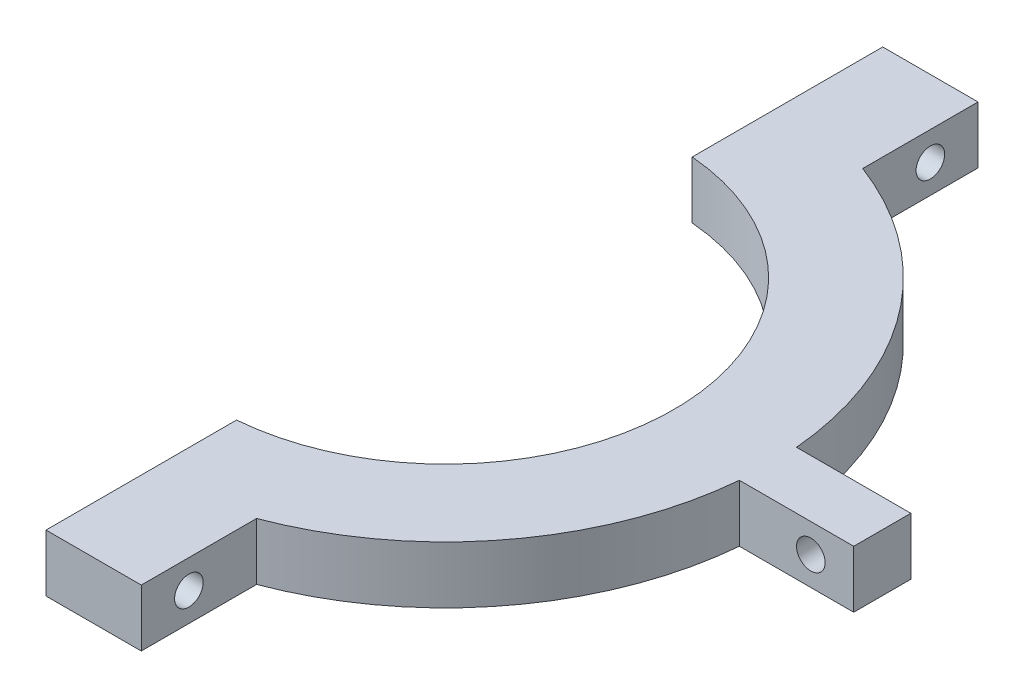
from build123d import *

# Parameters (mm, degrees)
BOSS_EXTRUDE1_DEPTH = 6
SKETCH3_R           = 1.5
CUT_EXTRUDE2_DEPTH  = 47.916521486
SKETCH4_R           = 1.5
CUT_EXTRUDE3_DEPTH  = 11


with BuildPart() as part:
    # Sketch1 → Boss-Extrude1 (new body)
    with BuildSketch(Plane(origin=(0, 0, 0), x_dir=(1, 0, 0), z_dir=(0, 1, 0))):
        with BuildLine():
            Line((2, 43.916521486), (2, 23.916521486))
            ThreePointArc((2, 23.916521486), (24, 0), (2, -23.916521486))
            Line((2, -23.916521486), (2, -43.916521486))
            Line((2, -43.916521486), (12, -43.916521486))
            Line((12, -43.916521486), (12, -31.811947441))
            ThreePointArc((12, -31.811947441), (27.082954224, -20.55513538), (33.867388444, -3))
            Line((33.867388444, -3), (45.867388444, -3))
            Line((45.867388444, -3), (45.867388444, 3))
            Line((45.867388444, 3), (33.867388444, 3))
            ThreePointArc((33.867388444, 3), (27.082954224, 20.55513538), (12, 31.811947441))
            Line((12, 31.811947441), (12, 43.916521486))
            Line((12, 43.916521486), (2, 43.916521486))
        make_face()
    extrude(amount=BOSS_EXTRUDE1_DEPTH)

    # Sketch3 → Cut-Extrude2 (cut, through all)
    with BuildSketch(Plane(origin=(0, 0, -3), x_dir=(-1, 0, 0), z_dir=(0, 0, -1))):
        with Locations((-41.367388444, 3)):
            Circle(SKETCH3_R)
    extrude(amount=-CUT_EXTRUDE2_DEPTH, mode=Mode.SUBTRACT)

    # Sketch4 → Cut-Extrude3 (cut, through all)
    with BuildSketch(Plane(origin=(12, 0, 0), x_dir=(0, 0, -1), z_dir=(1, 0, 0))):
        with Locations((-38.916521486, 3)):
            Circle(SKETCH4_R)
    cut_extrude3 = extrude(amount=-CUT_EXTRUDE3_DEPTH, mode=Mode.SUBTRACT)

    # Mirror1: Cut-Extrude3 across plane
    add(cut_extrude3.mirror(Plane.XY), mode=Mode.SUBTRACT)


solid = part.part
